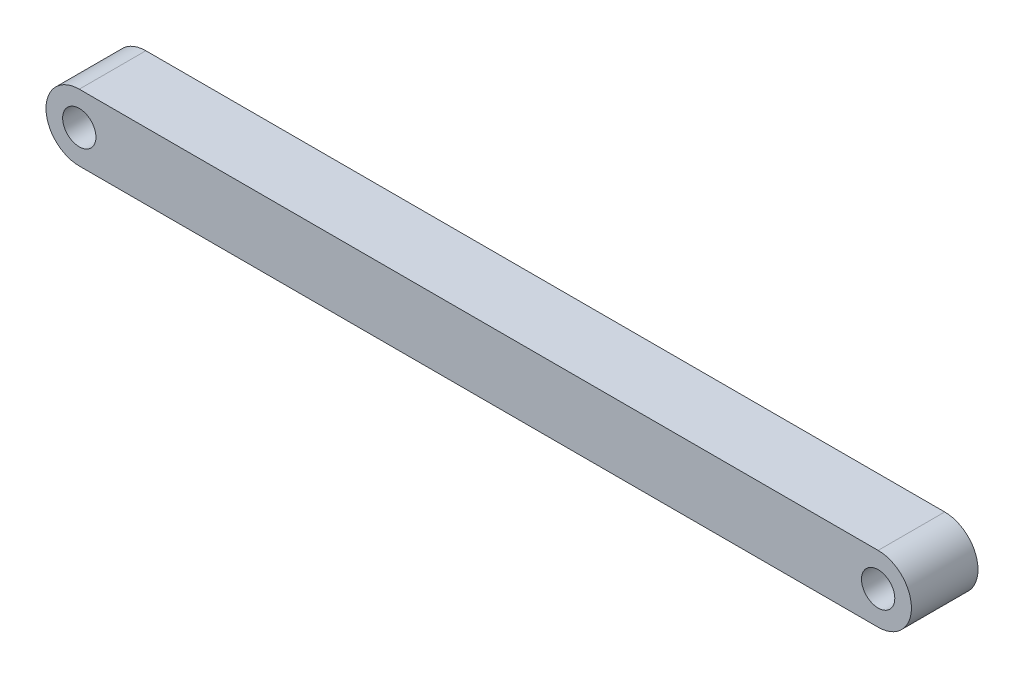
from build123d import *

# Parameters (mm, degrees)
SKETCH1_R           = 2.5
BOSS_EXTRUDE1_DEPTH = 10


with BuildPart() as part:
    # Sketch1 → Boss-Extrude1 (new body)
    with BuildSketch(Plane.XY):
        with BuildLine():
            Line((-60, 5), (60, 5))
            ThreePointArc((60, 5), (65, 0), (60, -5))
            Line((60, -5), (-60, -5))
            ThreePointArc((-60, -5), (-65, 0), (-60, 5))
        make_face()
        with Locations((-60, 0)):
            Circle(SKETCH1_R, mode=Mode.SUBTRACT)
        with Locations((60, 0)):
            Circle(SKETCH1_R, mode=Mode.SUBTRACT)
    extrude(amount=BOSS_EXTRUDE1_DEPTH)


solid = part.part
